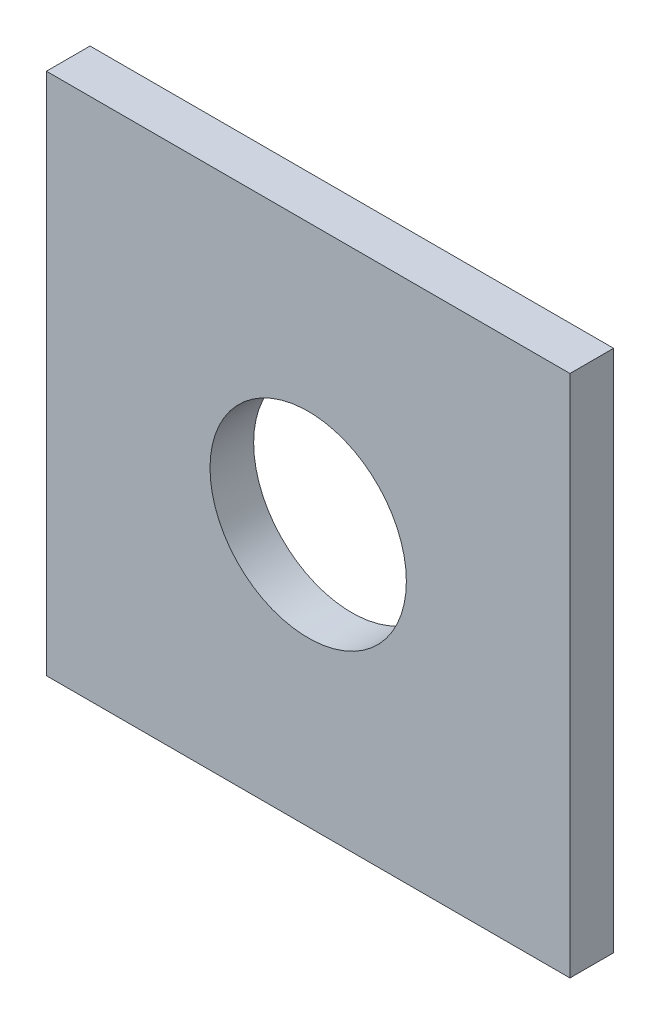
from build123d import *

# Parameters (mm, degrees)
SKETCH1_W           = 76.2
SKETCH1_H           = 76.2
BOSS_EXTRUDE1_DEPTH = 6.35
SKETCH3_R           = 14.2875
CUT_EXTRUDE1_DEPTH  = 7.35


with BuildPart() as part:
    # Sketch1 → Boss-Extrude1 (new body)
    with BuildSketch(Plane.XY):
        with Locations((-38.1, 38.1)):
            Rectangle(SKETCH1_W, SKETCH1_H)
    extrude(amount=BOSS_EXTRUDE1_DEPTH)

    # Sketch3 → Cut-Extrude1 (cut, through all)
    with BuildSketch(Plane.XY.offset(6.35)):
        with Locations((-38.1, 38.1)):
            Circle(SKETCH3_R)
    extrude(amount=-CUT_EXTRUDE1_DEPTH, mode=Mode.SUBTRACT)


solid = part.part
